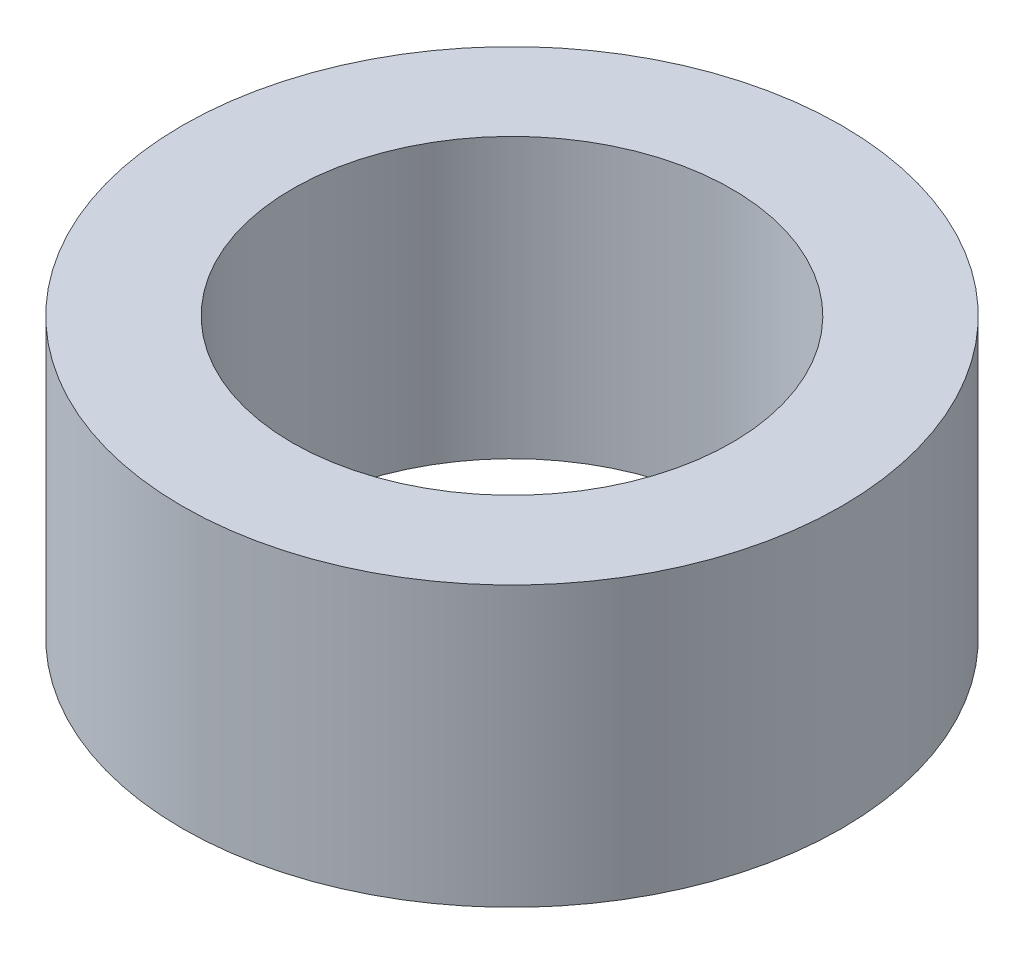
from build123d import *

# Parameters (mm, degrees)
SKETCH1_R           = 7.5
SKETCH1_R_2         = 5
BOSS_EXTRUDE1_DEPTH = 6.35


with BuildPart() as part:
    # Sketch1 → Boss-Extrude1 (new body)
    with BuildSketch(Plane(origin=(0, 0, 0), x_dir=(1, 0, 0), z_dir=(0, 1, 0))):
        Circle(SKETCH1_R)
        Circle(SKETCH1_R_2, mode=Mode.SUBTRACT)
    extrude(amount=BOSS_EXTRUDE1_DEPTH)


solid = part.part
